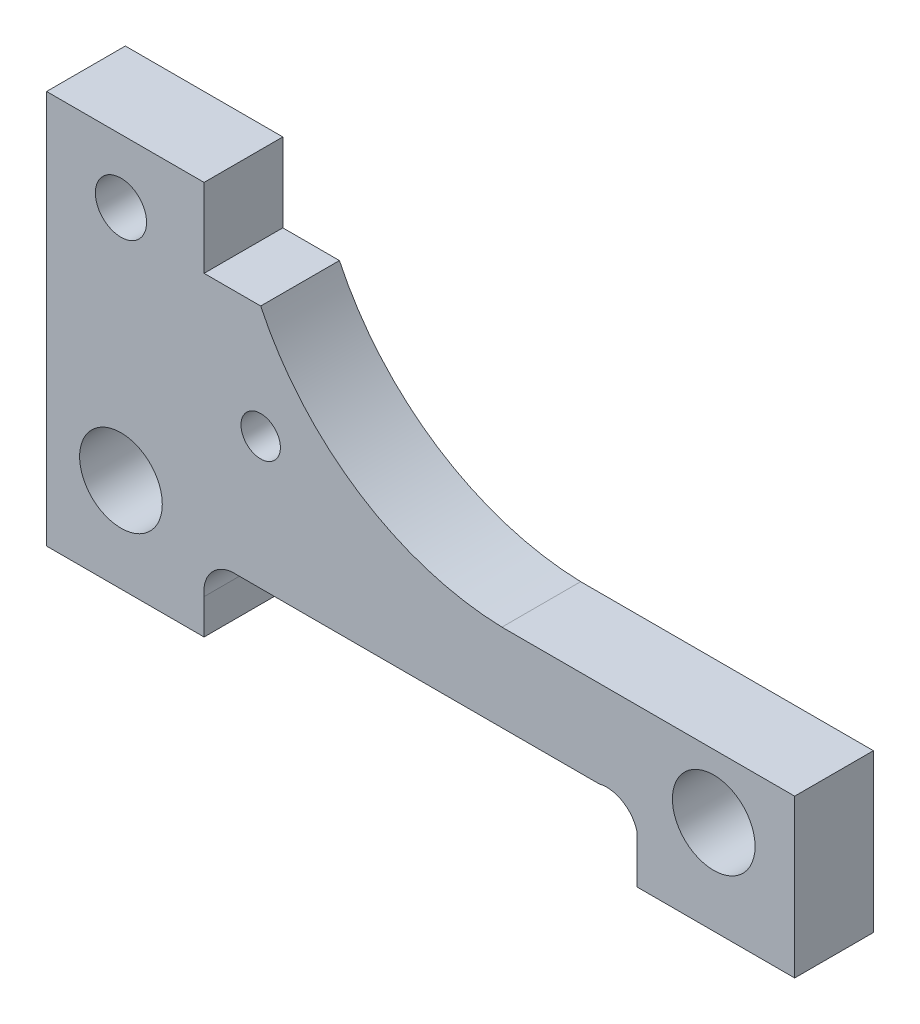
from build123d import *

# Parameters (mm, degrees)
SKETCH1_R           = 3.25
SKETCH1_R_2         = 5.25
SKETCH1_R_3         = 2.5
BOSS_EXTRUDE1_DEPTH = 10


with BuildPart() as part:
    # Sketch1 → Boss-Extrude1 (new body)
    with BuildSketch(Plane.XY):
        with BuildLine():
            Line((-42.222222222, -7.777777778), (-42.222222222, 42.222222222))
            Line((-42.222222222, 42.222222222), (-22.222222222, 42.222222222))
            Line((-22.222222222, 42.222222222), (-22.222222222, 32.222222222))
            Line((-22.222222222, 32.222222222), (-15.033488385, 32.222222222))
            ThreePointArc((-15.033488385, 32.222222222), (-2.53685568, 17.900528045), (15.60242755, 12.222222222))
            Line((15.60242755, 12.222222222), (52.777777778, 12.222222222))
            Line((52.777777778, 12.222222222), (52.777777778, -7.777777778))
            Line((52.777777778, -7.777777778), (32.777777778, -7.777777778))
            Line((32.777777778, -7.777777778), (32.777777778, -1.759068459))
            ThreePointArc((32.777777778, -1.759068459), (30.956018506, 0.70137381), (27.928044759, 1.152990889))
            Line((27.928044759, 1.152990889), (-18.776515477, 1.152990889))
            ThreePointArc((-18.776515477, 1.152990889), (-21.428517019, -0.376541989), (-22.222222222, -3.333333333))
            Line((-22.222222222, -3.333333333), (-22.222222222, -7.777777778))
            Line((-22.222222222, -7.777777778), (-42.222222222, -7.777777778))
        make_face()
        with Locations((-32.777777778, 34.166666667)):
            Circle(SKETCH1_R, mode=Mode.SUBTRACT)
        with Locations((-32.777777778, 4.166666667)):
            Circle(SKETCH1_R_2, mode=Mode.SUBTRACT)
        with Locations((-15.033488385, 17.900528045)):
            Circle(SKETCH1_R_3, mode=Mode.SUBTRACT)
        with Locations((42.5, 4.166666667)):
            Circle(SKETCH1_R_2, mode=Mode.SUBTRACT)
    extrude(amount=BOSS_EXTRUDE1_DEPTH)


solid = part.part
